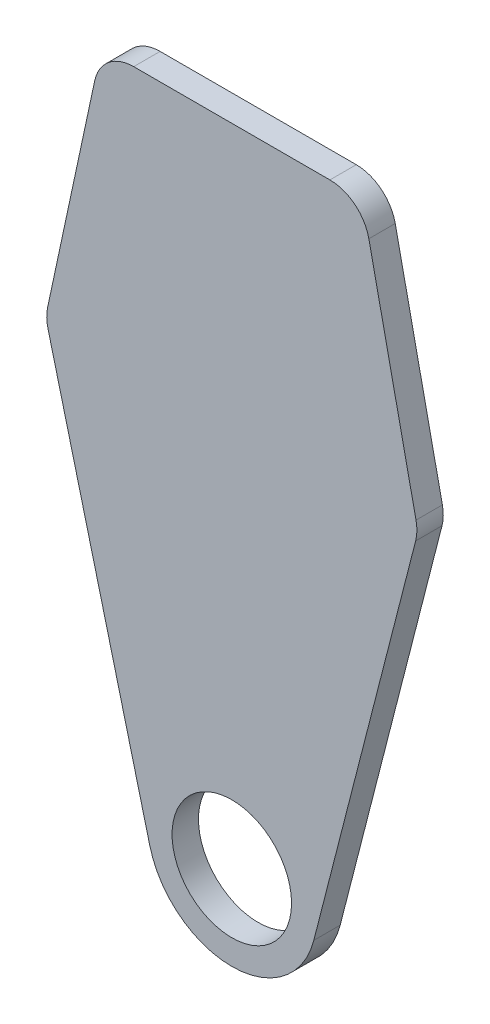
from build123d import *

# Parameters (mm, degrees)
SKETCH1_R           = 15.24
BOSS_EXTRUDE1_DEPTH = 6.731
FILLET1_R           = 10.16
FILLET2_R           = 10.16


with BuildPart() as part:
    # Sketch1 → Boss-Extrude1 (new body)
    with BuildSketch(Plane.XY):
        with BuildLine():
            Line((-33.2359, 164.676666667), (33.2359, 164.676666667))
            Line((33.2359, 164.676666667), (47.4853, 98.171))
            Line((47.4853, 98.171), (20.912246435, -5.367126704))
            ThreePointArc((20.912246435, -5.367126704), (0, -21.59), (-20.912246435, -5.367126704))
            Line((-20.912246435, -5.367126704), (-47.4853, 98.171))
            Line((-47.4853, 98.171), (-33.2359, 164.676666667))
        make_face()
        Circle(SKETCH1_R, mode=Mode.SUBTRACT)
    extrude(amount=BOSS_EXTRUDE1_DEPTH)

    # Fillet1
    fillet1_edges = [part.edges().sort_by_distance(p)[0] for p in [
        (-47.4853, 98.171, 3.3655),
        (47.4853, 98.171, 3.3655),
    ]]
    fillet(fillet1_edges, radius=FILLET1_R)

    # Fillet2
    fillet2_edges = [part.edges().sort_by_distance(p)[0] for p in [
        (-33.2359, 164.676666667, 3.3655),
        (33.2359, 164.676666667, 3.3655),
    ]]
    fillet(fillet2_edges, radius=FILLET2_R)


solid = part.part
